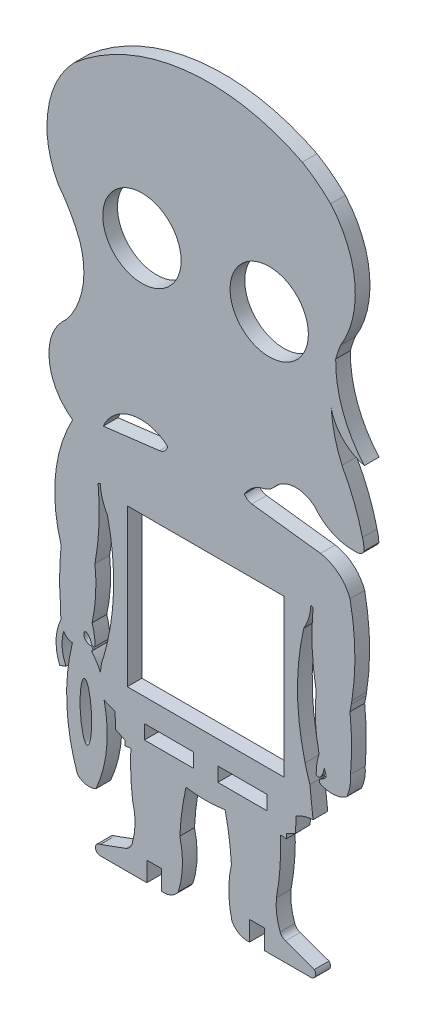
from build123d import *

# Parameters (mm, degrees)
MODEL_W                 = 10
MODEL_H                 = 2.9
MODEL_R                 = 8
SALIENTE_EXTRUIR1_DEPTH = 3


with BuildPart() as part:
    # Model → Saliente-Extruir1 (new body)
    with BuildSketch(Plane.XY):
        with BuildLine():
            ThreePointArc((17.486512664, -5.20688981), (16.460575392, -9.328354705), (17.215371861, -13.50798417))
            Line((17.215371861, -13.50798417), (18.485374445, -13.014423848))
            ThreePointArc((18.485374445, -13.014423848), (17.714623282, -10.084157705), (18.004916344, -7.068159203))
            ThreePointArc((18.004916344, -7.068159203), (18.765050671, -7.849962368), (19.799365359, -8.195235462))
            ThreePointArc((19.799365359, -8.195235462), (18.654637675, -19.630191514), (20.803682737, -30.919577089))
            ThreePointArc((20.803682737, -30.919577089), (22.590964749, -31.884529296), (24.604929427, -31.620984188))
            ThreePointArc((24.604929427, -31.620984188), (26.779287611, -23.494990909), (26.273358309, -15.098346589))
            Line((26.273358309, -15.098346589), (28.496601304, -16.009026468))
            Line((28.496601304, -16.009026468), (28.646493018, -19.147086539))
            Line((28.646493018, -19.147086539), (30.503019056, -20.047044626))
            Line((30.503019056, -20.047044626), (30.503165401, -21.047044615))
            Line((30.503165401, -21.047044615), (31.728695139, -20.920869065))
            ThreePointArc((31.728695139, -20.920869065), (31.716397553, -25.456302262), (32.083693246, -29.976855257))
            ThreePointArc((32.083693246, -29.976855257), (32.585408283, -33.519323773), (32.120653166, -37.06683048))
            ThreePointArc((32.120653166, -37.06683048), (31.687308476, -38.306685331), (30.665341785, -39.131677302))
            Line((30.665341785, -39.131677302), (25.463171688, -41.040465647))
            ThreePointArc((25.463171688, -41.040465647), (24.49258217, -42.065480857), (25.506385034, -43.047776102))
            Line((25.506385034, -43.047776102), (35.005127475, -43.046386013))
            Line((35.005127475, -43.046386013), (35.004542097, -39.046386056))
            Line((35.004542097, -39.046386056), (38.000345095, -39.045947637))
            Line((38.000345095, -39.045947637), (38.005127305, -43.045004855))
            ThreePointArc((38.005127305, -43.045004855), (39.943419857, -42.749032738), (41.420044934, -41.459011074))
            ThreePointArc((41.420044934, -41.459011074), (42.271424769, -36.468808969), (41.739856235, -31.434486814))
            ThreePointArc((41.739856235, -31.434486814), (42.165076895, -26.766639993), (42.997476286, -22.153970722))
            ThreePointArc((42.997476286, -22.153970722), (47.001230774, -22.470613254), (51.00493888, -22.153384798))
            ThreePointArc((51.00493888, -22.153384798), (51.818537465, -26.644880805), (52.278308829, -31.186256072))
            ThreePointArc((52.278308829, -31.186256072), (51.747113849, -36.172536413), (52.389392925, -41.145728278))
            ThreePointArc((52.389392925, -41.145728278), (53.899711048, -42.656451669), (56.000345095, -43.044630229))
            Line((56.000345095, -43.044630229), (56.000345095, -39.044630229))
            Line((56.000345095, -39.044630229), (59.000345095, -39.044630229))
            Line((59.000345095, -39.044630229), (59.000345095, -43.044630229))
            Line((59.000345095, -43.044630229), (68.53735027, -43.04422893))
            ThreePointArc((68.53735027, -43.04422893), (69.437251793, -42.384190072), (69.220597323, -41.289413892))
            Line((69.220597323, -41.289413892), (63.321274836, -39.168668007))
            ThreePointArc((63.321274836, -39.168668007), (62.641433043, -38.790724912), (62.234355358, -38.127917546))
            ThreePointArc((62.234355358, -38.127917546), (61.523569867, -35.340724971), (61.470991337, -32.464808776))
            ThreePointArc((61.470991337, -32.464808776), (62.207027112, -26.714989922), (62.273539448, -20.918634029))
            Line((62.273539448, -20.918634029), (63.499087639, -21.044630229))
            Line((63.499087639, -21.044630229), (63.499087639, -20.044630229))
            Line((63.499087639, -20.044630229), (65.355481953, -19.14440046))
            Line((65.355481953, -19.14440046), (65.504914428, -16.006318486))
            ThreePointArc((65.504914428, -16.006318486), (67.157634301, -15.244964242), (68.952461972, -14.945403065))
            Line((68.952461972, -14.945403065), (68.305653668, -9.004064763))
            ThreePointArc((68.305653668, -9.004064763), (67.790080511, -7.351279724), (67.332555736, -5.681493766))
            ThreePointArc((67.332555736, -5.681493766), (65.778035915, 6.15449932), (67.064539301, 18.022615145))
            ThreePointArc((67.064539301, 18.022615145), (68.085329906, 20.311452445), (68.505560117, 22.782119605))
            Line((68.505560117, 22.782119605), (68.956696878, 22.603527949))
            ThreePointArc((68.956696878, 22.603527949), (68.777291985, 15.312567014), (69.600194394, 8.065972704))
            ThreePointArc((69.600194394, 8.065972704), (69.452190454, 2.676813935), (70.180246445, -2.664990242))
            ThreePointArc((70.180246445, -2.664990242), (69.717834189, -4.612479173), (69.594827044, -6.610329886))
            ThreePointArc((69.594827044, -6.610329886), (69.976382842, -6.791945919), (70.387036504, -6.692282589))
            ThreePointArc((70.387036504, -6.692282589), (70.967215172, -5.70743896), (71.2095152, -4.590382579))
            Line((71.2095152, -4.590382579), (71.575127035, -5.5723563))
            ThreePointArc((71.575127035, -5.5723563), (71.559868259, -6.126540852), (71.191781006, -6.541107037))
            ThreePointArc((71.191781006, -6.541107037), (70.763080574, -6.801657443), (70.362941141, -7.104244633))
            ThreePointArc((70.362941141, -7.104244633), (70.237940792, -7.485262746), (70.438507812, -7.832498631))
            ThreePointArc((70.438507812, -7.832498631), (73.041558053, -8.369706377), (75.590958408, -7.618027891))
            ThreePointArc((75.590958408, -7.618027891), (75.795489253, -7.446698958), (75.933260543, -7.218213639))
            ThreePointArc((75.933260543, -7.218213639), (76.512760478, -5.207882007), (76.610684894, -3.117986256))
            ThreePointArc((76.610684894, -3.117986256), (76.706768283, -1.834872699), (76.774262501, -0.54993809))
            ThreePointArc((76.774262501, -0.54993809), (76.823637912, 1.792813394), (76.77800376, 4.135640741))
            ThreePointArc((76.77800376, 4.135640741), (76.67019552, 6.047816322), (76.499087639, 7.955369771))
            ThreePointArc((76.499087639, 7.955369771), (76.643892765, 8.693181636), (76.777589027, 9.433087158))
            Line((76.777589027, 9.433087158), (76.892053598, 10.123708789))
            ThreePointArc((76.892053598, 10.123708789), (77.496947302, 19.057199651), (76.499087639, 27.955369771))
            ThreePointArc((76.499087639, 27.955369771), (74.162998731, 31.252063082), (70.499087639, 32.955369771))
            Line((70.499087639, 32.955369771), (56.440257283, 34.677767378))
            ThreePointArc((56.440257283, 34.677767378), (55.565350811, 35.004667038), (54.934284221, 35.693201482))
            ThreePointArc((54.934284221, 35.693201482), (56.34261397, 37.349996258), (58.226336915, 38.436251051))
            ThreePointArc((58.226336915, 38.436251051), (58.491758528, 38.523194616), (58.762600218, 38.591404548))
            ThreePointArc((58.762600218, 38.591404548), (60.012064881, 39.091666168), (61.024875843, 39.978028163))
            ThreePointArc((61.024875843, 39.978028163), (65.064692235, 42.07888298), (69.361594362, 40.572118382))
            ThreePointArc((69.361594362, 40.572118382), (72.936315566, 37.739659967), (77.409486842, 36.849608791))
            ThreePointArc((77.409486842, 36.849608791), (77.638748428, 36.854494158), (77.868029254, 36.850615421))
            ThreePointArc((77.868029254, 36.850615421), (78.776060323, 37.093109411), (79.392847633, 37.802261842))
            ThreePointArc((79.392847633, 37.802261842), (79.297892701, 38.931077147), (79.04219458, 40.034643593))
            ThreePointArc((79.04219458, 40.034643593), (77.31859392, 45.516653875), (74.861665807, 50.711530217))
            ThreePointArc((74.861665807, 50.711530217), (73.376897769, 55.141753681), (72.664832014, 59.759586336))
            ThreePointArc((72.664832014, 59.759586336), (75.083712073, 55.397473033), (79.43235084, 52.954451526))
            ThreePointArc((79.43235084, 52.954451526), (75.023723673, 60.37352971), (73.579632879, 68.881955908))
            ThreePointArc((73.579632879, 68.881955908), (74.02529603, 70.345640531), (74.551802627, 71.782226457))
            ThreePointArc((74.551802627, 71.782226457), (77.515808527, 84.145544413), (72.543691638, 95.846613401))
            ThreePointArc((72.543691638, 95.846613401), (69.787552342, 98.260204265), (66.752920717, 100.312699229))
            ThreePointArc((66.752920717, 100.312699229), (42.602784341, 104.573894348), (20.187953513, 94.625918184))
            ThreePointArc((20.187953513, 94.625918184), (16.481005838, 89.273773606), (14.756380247, 82.995829738))
            ThreePointArc((14.756380247, 82.995829738), (14.899123124, 77.119059209), (16.829484817, 71.566536259))
            ThreePointArc((16.829484817, 71.566536259), (19.356873579, 67.77173692), (21.301561495, 63.647857085))
            ThreePointArc((21.301561495, 63.647857085), (21.875005661, 55.598452202), (18.484212058, 48.275592384))
            ThreePointArc((18.484212058, 48.275592384), (16.076161614, 45.241196984), (15.046759527, 41.50668313))
            ThreePointArc((15.046759527, 41.50668313), (16.080068715, 35.743447006), (19.837500151, 31.252976263))
            ThreePointArc((19.837500151, 31.252976263), (16.336106105, 19.80960411), (17.494522742, 7.898743629))
            ThreePointArc((17.494522742, 7.898743629), (17.177500989, 2.382494047), (17.387147575, -3.138879022))
            ThreePointArc((17.387147575, -3.138879022), (17.376740758, -4.175771627), (17.486512664, -5.20688981))
        make_face()
        with BuildLine():
            add(Edge.make_bspline(
                [(22.298106267, -13.288382903), (20.295159496, -13.375279498), (21.671606368, -21.974884842), (23.04805324, -30.574490185), (23.674553139, -21.887988246), (24.301053038, -13.201486307), (22.298106267, -13.288382903)],
                knots=[0, 0, 0, 2.094395102, 2.094395102, 4.188790205, 4.188790205, 6.283185307, 6.283185307, 6.283185307], degree=2, weights=[1, 0.5, 1, 0.5, 1, 0.5, 1]))
        make_face(mode=Mode.SUBTRACT)
        with Locations((39.500345095, -16.594630229)):
            Rectangle(MODEL_W, MODEL_H, mode=Mode.SUBTRACT)
        with BuildLine():
            ThreePointArc((24.399524996, 8.066732501), (25.224814007, 15.313204212), (25.043511247, 22.604266104))
            Line((25.043511247, 22.604266104), (25.491004481, 22.781397995))
            ThreePointArc((25.491004481, 22.781397995), (25.915693184, 20.289957389), (26.945102641, 17.981721493))
            ThreePointArc((26.945102641, 17.981721493), (28.227317248, 6.740517223), (26.955952045, -4.501919267))
            ThreePointArc((26.955952045, -4.501919267), (26.389378678, -6.725085682), (25.722700343, -8.92031102))
            Line((25.722700343, -8.92031102), (25.526105485, -10.565796601))
            ThreePointArc((25.526105485, -10.565796601), (24.706154519, -9.069739124), (23.68663127, -7.701864896))
            ThreePointArc((23.68663127, -7.701864896), (23.97072194, -7.23434447), (23.582753878, -6.84864557))
            ThreePointArc((23.582753878, -6.84864557), (22.520756504, -6.419575027), (22.126726752, -5.344084206))
            ThreePointArc((22.126726752, -5.344084206), (22.338421625, -4.953440601), (22.781938959, -4.980077424))
            ThreePointArc((22.781938959, -4.980077424), (23.336790386, -5.550915748), (23.631288116, -6.290501838))
            ThreePointArc((23.631288116, -6.290501838), (23.829379322, -6.649525073), (24.230958108, -6.732424338))
            ThreePointArc((24.230958108, -6.732424338), (24.319710103, -6.680659161), (24.398812393, -6.61508952))
            ThreePointArc((24.398812393, -6.61508952), (24.283046568, -4.61410738), (23.819112182, -2.664210938))
            ThreePointArc((23.819112182, -2.664210938), (24.550086194, 2.677420644), (24.399524996, 8.066732501))
        make_face(mode=Mode.SUBTRACT)
        Polygon((31.000345095, 21.633403788), (47.500345095, 21.633403788), (63.000345095, 21.633403788), (63.000345095, -10.366596212), (31.000345095, -10.366596212), align=None, mode=Mode.SUBTRACT)
        with Locations((54.500345095, -16.594630229)):
            Rectangle(MODEL_W, MODEL_H, mode=Mode.SUBTRACT)
        with BuildLine():
            Line((37.560356758, 34.678084738), (26.095810782, 33.273913401))
            ThreePointArc((26.095810782, 33.273913401), (31.929707377, 38.106530958), (39.273208939, 36.246013084))
            ThreePointArc((39.273208939, 36.246013084), (38.667640549, 35.188004398), (37.560356758, 34.678084738))
        make_face(mode=Mode.SUBTRACT)
        with Locations((34.000345095, 70.477413033)):
            Circle(MODEL_R, mode=Mode.SUBTRACT)
        with Locations((60.000345095, 70.477413033)):
            Circle(MODEL_R, mode=Mode.SUBTRACT)
    extrude(amount=SALIENTE_EXTRUIR1_DEPTH)


solid = part.part
